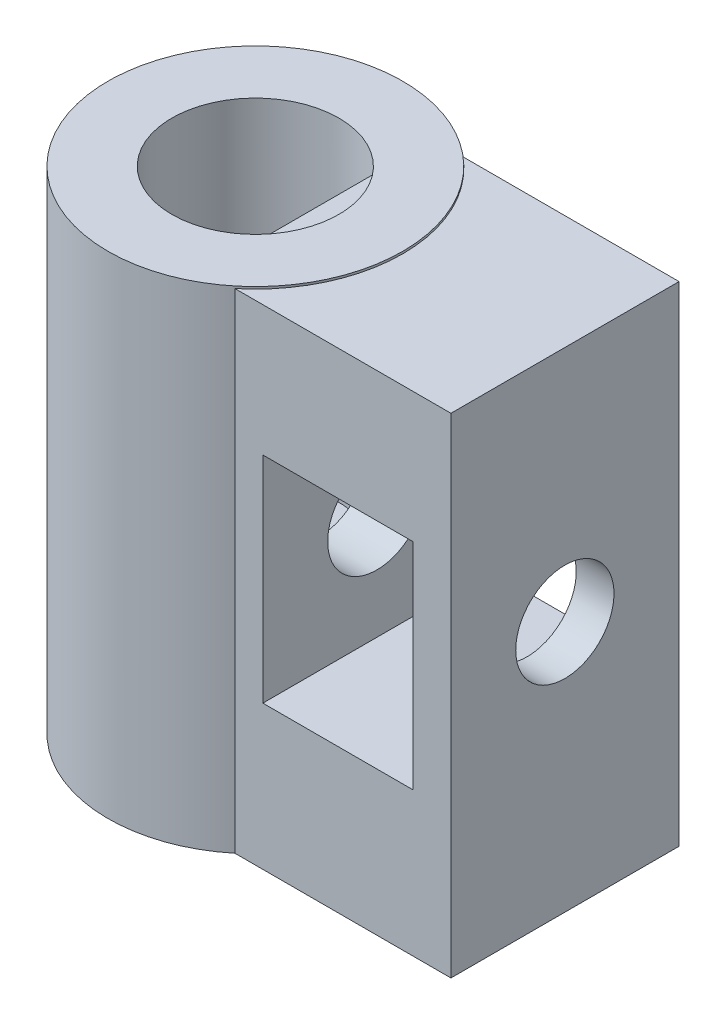
from build123d import *

# Parameters (mm, degrees)
SKETCH1_R               = 6
BOSS_EXTRUDE1_DEPTH     = 20
SKETCH2_R               = 3.4
CUT_EXTRUDE1_DEPTH      = 13.55
SKETCH5_W               = 1.550685087
SKETCH5_H               = 7.184215806
BOSS_EXTRUDE2_DEPTH     = 13.55
SKETCH7_W               = 9.286501956
SKETCH7_H               = 19.909960041
BOSS_EXTRUDE3_DEPTH     = 10
CUT_EXTRUDE2_DEPTH      = 1
CUT_EXTRUDE2_DEPTH_BACK = 13.55
SKETCH6_R               = 2
CUT_EXTRUDE3_DEPTH      = 10
CUT_EXTRUDE3_DEPTH_BACK = 10


with BuildPart() as part:
    # Sketch1 → Boss-Extrude1 (new body)
    with BuildSketch(Plane(origin=(0, 0, 0), x_dir=(1, 0, 0), z_dir=(0, 1, 0))):
        Circle(SKETCH1_R)
    extrude(amount=BOSS_EXTRUDE1_DEPTH)

    # Sketch2 → Cut-Extrude1 (cut)
    with BuildSketch(Plane(origin=(0, 20, 0), x_dir=(1, 0, 0), z_dir=(0, 1, 0))):
        Circle(SKETCH2_R)
    extrude(amount=-CUT_EXTRUDE1_DEPTH, mode=Mode.SUBTRACT)

    # Sketch5 → Boss-Extrude2 (add)
    with BuildSketch(Plane(origin=(0, 18.26, 0), x_dir=(1, 0, 0), z_dir=(0, 1, 0))):
        with Locations((3.375342544, 0.020519704)):
            Rectangle(SKETCH5_W, SKETCH5_H)
    extrude(amount=-BOSS_EXTRUDE2_DEPTH)

    # Sketch7 → Boss-Extrude3 (add)
    with BuildSketch(Plane.ZY.offset(-2.6)):
        with Locations((-0.005218197, 9.954980021)):
            Rectangle(SKETCH7_W, SKETCH7_H)
    extrude(amount=-BOSS_EXTRUDE3_DEPTH)

    # Sketch6 → Cut-Extrude2 (cut, two sides: drawn at the far end of the back side and taken through both)
    with BuildSketch(Plane.ZY.offset(-2.6).offset(-CUT_EXTRUDE2_DEPTH_BACK)):
        with Locations((0, 10.236925537)):
            Circle(SKETCH6_R)
    extrude(amount=CUT_EXTRUDE2_DEPTH + CUT_EXTRUDE2_DEPTH_BACK, mode=Mode.SUBTRACT)

    # Sketch9 → Cut-Extrude3 (cut, two sides: drawn at the far end of the back side and taken through both)
    with BuildSketch(Plane.XY.offset(-CUT_EXTRUDE3_DEPTH_BACK)):
        Polygon((11.063430227, 10.236925537), (11.063430227, 5.861925537), (4.943430227, 5.861925537), (4.943430227, 10.236925537), (4.943430227, 14.611925537), (11.063430227, 14.611925537), align=None)
    extrude(amount=CUT_EXTRUDE3_DEPTH + CUT_EXTRUDE3_DEPTH_BACK, mode=Mode.SUBTRACT)


solid = part.part
